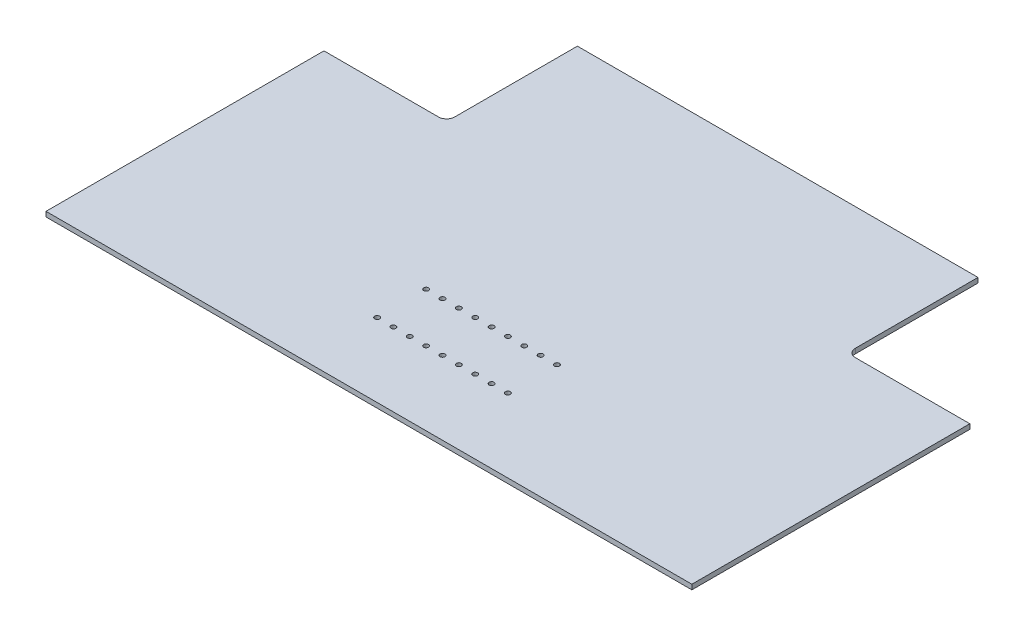
from build123d import *

# Parameters (mm, degrees)
SKETCH1_W           = 395
SKETCH1_H           = 250
BOSS_EXTRUDE1_DEPTH = 3
SKETCH2_W           = 75
SKETCH2_H           = 80
CUT_EXTRUDE1_DEPTH  = 3
SKETCH3_R           = 1.5
CUT_EXTRUDE2_DEPTH  = 10
FILLET1_R           = 5
LPATTERN1_COUNT     = 5
LPATTERN1_PITCH     = 10
LPATTERN1_COL_COUNT = 5
LPATTERN1_COL_PITCH = 10


with BuildPart() as part:
    # Sketch1 → Boss-Extrude1 (new body)
    with BuildSketch(Plane(origin=(0, 0, 0), x_dir=(1, 0, 0), z_dir=(0, 1, 0))):
        Rectangle(SKETCH1_W, SKETCH1_H)
    extrude(amount=BOSS_EXTRUDE1_DEPTH)

    # Sketch2 → Cut-Extrude1 (cut)
    with BuildSketch(Plane(origin=(0, 3, 0), x_dir=(1, 0, 0), z_dir=(0, 1, 0))):
        with Locations((-160, 85)):
            Rectangle(SKETCH2_W, SKETCH2_H)
    cut_extrude1 = extrude(amount=-CUT_EXTRUDE1_DEPTH, mode=Mode.SUBTRACT)

    # Mirror1: Cut-Extrude1 across plane
    add(cut_extrude1.mirror(Plane(origin=(0, 0, 0), x_dir=(0, 0, 1), z_dir=(1, 0, 0))), mode=Mode.SUBTRACT)

    # Sketch3 → Cut-Extrude2 (cut)
    with BuildSketch(Plane(origin=(0, 3, 0), x_dir=(1, 0, 0), z_dir=(0, 1, 0))):
        with Locations((0, -50)):
            Circle(SKETCH3_R)
        with Locations((0, -80)):
            Circle(SKETCH3_R)
    cut_extrude2 = extrude(amount=-CUT_EXTRUDE2_DEPTH, mode=Mode.SUBTRACT)

    # Fillet1
    fillet1_edges = [part.edges().sort_by_distance(p)[0] for p in [
        (-122.5, 1.5, -45),
        (122.5, 1.5, -45),
    ]]
    fillet(fillet1_edges, radius=FILLET1_R)

    # LPattern1: Cut-Extrude2 ×5
    with Locations(*[(-i * LPATTERN1_PITCH, 0, 0) for i in range(1, LPATTERN1_COUNT)]):
        add(cut_extrude2, mode=Mode.SUBTRACT)

    # LPattern1 col: Cut-Extrude2 ×5
    with Locations(*[(i * LPATTERN1_COL_PITCH, 0, 0) for i in range(1, LPATTERN1_COL_COUNT)]):
        add(cut_extrude2, mode=Mode.SUBTRACT)


solid = part.part
